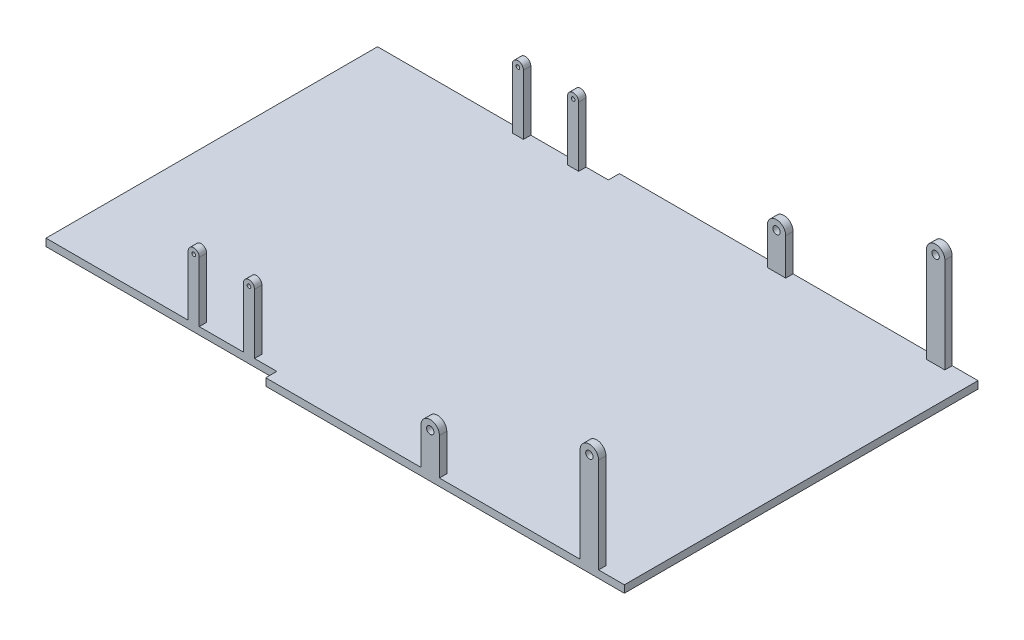
from build123d import *

# Parameters (mm, degrees)
BOSS_EXTRUDE1_DEPTH = 20
SKETCH2_R           = 10
BOSS_EXTRUDE2_DEPTH = 20
SKETCH3_R           = 5
BOSS_EXTRUDE3_DEPTH = 20


with BuildPart() as part:
    # Sketch1 → Boss-Extrude1 (new body)
    with BuildSketch(Plane(origin=(0, 0, 0), x_dir=(1, 0, 0), z_dir=(0, 1, 0))):
        Polygon((-173.422280891, 480), (-173.422280891, 450), (-800, 450), (-800, -450), (-173.422280891, -450), (-173.422280891, -480), (800, -480), (800, 480), align=None)
    extrude(amount=-BOSS_EXTRUDE1_DEPTH)

    # Sketch2 → Boss-Extrude2 (add)
    with BuildSketch(Plane.XY.offset(480)):
        with BuildLine():
            Line((248, 0), (298, 0))
            Line((298, 0), (298, 100))
            ThreePointArc((298, 100), (273, 125), (248, 100))
            Line((248, 100), (248, 0))
        make_face()
        with Locations((273, 100)):
            Circle(SKETCH2_R, mode=Mode.SUBTRACT)
        with BuildLine():
            Line((680, 258.2), (680, 0))
            Line((680, 0), (730, 0))
            Line((730, 0), (730, 258.2))
            ThreePointArc((730, 258.2), (705, 283.2), (680, 258.2))
        make_face()
        with Locations((705, 258.2)):
            Circle(SKETCH2_R, mode=Mode.SUBTRACT)
        Polygon((680, 0), (298, 0), (248, 0), (-173.422280891, 0), (-173.422280891, -20), (800, -20), (800, 0), (730, 0), align=None)
    extrude(amount=-BOSS_EXTRUDE2_DEPTH)

    # Mirror1: part across plane


with BuildPart() as part_1:
    add(part.part)
    add(part.part.mirror(Plane.XY))

    # Sketch3 → Boss-Extrude3 (add)
    with BuildSketch(Plane.XY.offset(450)):
        with BuildLine():
            Line((-414, 0), (-384, 0))
            Line((-384, 0), (-384, 162.7))
            ThreePointArc((-384, 162.7), (-399, 177.7), (-414, 162.7))
            Line((-414, 162.7), (-414, 0))
        make_face()
        with Locations((-399, 162.7)):
            Circle(SKETCH3_R, mode=Mode.SUBTRACT)
        with BuildLine():
            Line((-264, 0), (-234, 0))
            Line((-234, 0), (-234, 162.7))
            ThreePointArc((-234, 162.7), (-249, 177.7), (-264, 162.7))
            Line((-264, 162.7), (-264, 0))
        make_face()
        with Locations((-249, 162.7)):
            Circle(SKETCH3_R, mode=Mode.SUBTRACT)
    boss_extrude3 = extrude(amount=-BOSS_EXTRUDE3_DEPTH)

    # Mirror2: Boss-Extrude3 across plane
    add(boss_extrude3.mirror(Plane.XY))


solid = part_1.part
